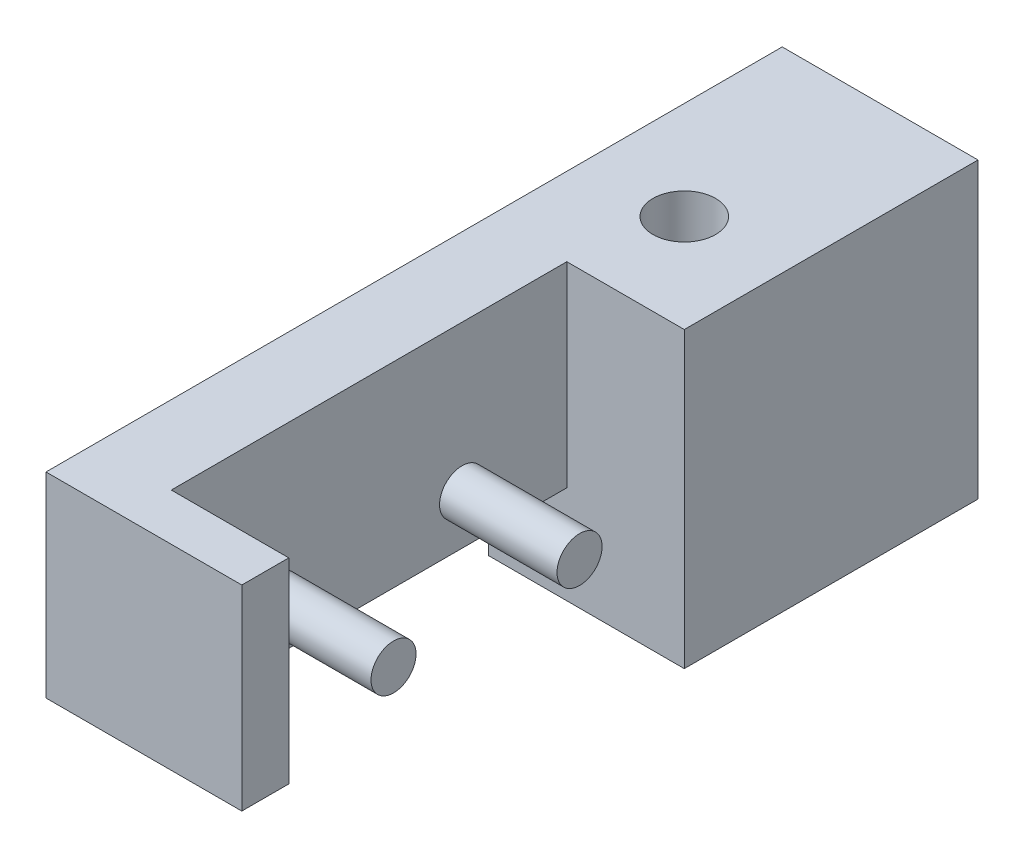
from build123d import *

# Parameters (mm, degrees)
EXTRUDE_1_DEPTH     = 5
SKETCH_2_W          = 20.2
SKETCH_2_H          = 10
CUT_EXTRUDE_1_DEPTH = 6
SKETCH_3_R          = 1.15
EXTRUDE_2_DEPTH     = 6
CUT_EXTRUDE_2_REACH = 17
SKETCH_5_R          = 1.6


with BuildPart() as part:
    # 草图1 → 凸台-拉伸1 (new body, symmetric)
    with BuildSketch(Plane(origin=(0, 0, 0), x_dir=(0, 0, -1), z_dir=(1, 0, 0))):
        Polygon((0, 0), (15, 0), (15, 15), (-22.6, 15), (-22.6, 5), (0, 5), (0, 4), align=None)
    extrude(amount=EXTRUDE_1_DEPTH, both=True)

    # 草图2 → 切除-拉伸1 (cut)
    with BuildSketch(Plane(origin=(5, 0, 0), x_dir=(0, 0, -1), z_dir=(1, 0, 0))):
        with Locations((-10.1, 10)):
            Rectangle(SKETCH_2_W, SKETCH_2_H)
    extrude(amount=-CUT_EXTRUDE_1_DEPTH, mode=Mode.SUBTRACT)

    # 草图3 → 凸台-拉伸2 (add)
    with BuildSketch(Plane(origin=(-1, 0, 0), x_dir=(0, 0, -1), z_dir=(1, 0, 0))):
        with Locations((-14.85, 7.5)):
            Circle(SKETCH_3_R)
        with Locations((-5.35, 7.5)):
            Circle(SKETCH_3_R)
    extrude(amount=EXTRUDE_2_DEPTH)

    # 草图5 → 切除-拉伸2 (cut, up to next)
    with BuildSketch(Plane.XZ, mode=Mode.PRIVATE) as cut_extrude_2_sk1:
        with Locations((0, -5)):
            Circle(SKETCH_5_R)
    cut_extrude_2_tool1 = extrude(cut_extrude_2_sk1.sketch, amount=-CUT_EXTRUDE_2_REACH, mode=Mode.PRIVATE) & part.part
    add(cut_extrude_2_tool1.solids().sort_by_distance((0, 0, -5))[0], mode=Mode.SUBTRACT)


solid = part.part
